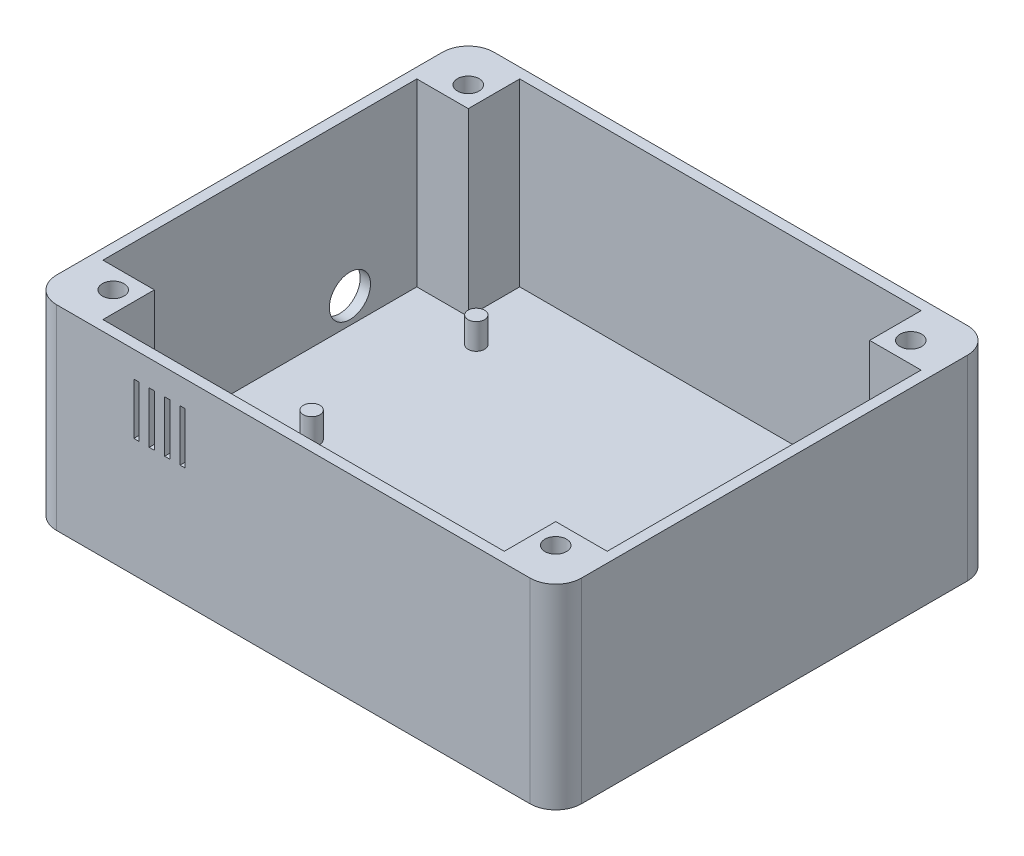
from build123d import *

# Parameters (mm, degrees)
SKETCH1_W           = 102
SKETCH1_H           = 85
BOSS_EXTRUDE1_DEPTH = 38
SKETCH2_R           = 2.1
CUT_EXTRUDE1_DEPTH  = 35
SKETCH3_R           = 2.1
CUT_EXTRUDE2_DEPTH  = 35
SKETCH5_R           = 4
CUT_EXTRUDE4_DEPTH  = 10
FILLET1_R           = 5
FILLET2_R           = 5
FILLET3_R           = 5
FILLET4_R           = 5
SKETCH6_R           = 1.6
BOSS_EXTRUDE2_DEPTH = 5
SKETCH7_W           = 15
SKETCH7_H           = 4
BOSS_EXTRUDE3_DEPTH = 12
CHAMFER1_SIZE       = 5
CHAMFER2_SIZE       = 5
SKETCH8_R           = 3.012300636
CUT_EXTRUDE5_DEPTH  = 5
FILLET5_R           = 2
FILLET6_R           = 2
FILLET7_R           = 2
FILLET8_R           = 2
SKETCH9_W           = 1
SKETCH9_H           = 10
CUT_EXTRUDE6_DEPTH  = 2.1
SKETCH10_W          = 1
SKETCH10_H          = 10
CUT_EXTRUDE7_DEPTH  = 2.1


with BuildPart() as part:
    # Sketch1 → Boss-Extrude1 (new body)
    with BuildSketch(Plane(origin=(0, 0, 0), x_dir=(1, 0, 0), z_dir=(0, 1, 0))):
        Rectangle(SKETCH1_W, SKETCH1_H)
    extrude(amount=BOSS_EXTRUDE1_DEPTH)

    # Sketch2 → Cut-Extrude1 (cut)
    with BuildSketch(Plane(origin=(0, 38, 0), x_dir=(1, 0, 0), z_dir=(0, 1, 0))):
        with Locations((43, 34.5)):
            Circle(SKETCH2_R)
        with Locations((-43, -34.5)):
            Circle(SKETCH2_R)
        with Locations((43, -34.5)):
            Circle(SKETCH2_R)
        Polygon((-39, 40.5), (39, 40.5), (39, 30.5), (49, 30.5), (49, -30.5), (39, -30.5), (39, -40.5), (-39, -40.5), (-39, -30.5), (-49, -30.5), (-49, 30.5), (-39, 30.5), align=None)
    extrude(amount=-CUT_EXTRUDE1_DEPTH, mode=Mode.SUBTRACT)

    # Sketch3 → Cut-Extrude2 (cut)
    with BuildSketch(Plane(origin=(0, 38, 0), x_dir=(1, 0, 0), z_dir=(0, 1, 0))):
        with Locations((-43, 34.5)):
            Circle(SKETCH3_R)
    extrude(amount=-CUT_EXTRUDE2_DEPTH, mode=Mode.SUBTRACT)

    # Sketch5 → Cut-Extrude4 (cut)
    with BuildSketch(Plane.ZY.offset(51)):
        with Locations((-17.5, 7.998461061)):
            Circle(SKETCH5_R)
        with Locations((17.5, 7.998461061)):
            Circle(SKETCH5_R)
    extrude(amount=-CUT_EXTRUDE4_DEPTH, mode=Mode.SUBTRACT)

    # Fillet1
    fillet1_edges = [part.edges().sort_by_distance(p)[0] for p in [
        (-51, 19, 42.5),
    ]]
    fillet(fillet1_edges, radius=FILLET1_R)

    # Fillet2
    fillet2_edges = [part.edges().sort_by_distance(p)[0] for p in [
        (-51, 19, -42.5),
    ]]
    fillet(fillet2_edges, radius=FILLET2_R)

    # Fillet3
    fillet3_edges = [part.edges().sort_by_distance(p)[0] for p in [
        (51, 19, 42.5),
    ]]
    fillet(fillet3_edges, radius=FILLET3_R)

    # Fillet4
    fillet4_edges = [part.edges().sort_by_distance(p)[0] for p in [
        (51, 19, -42.5),
    ]]
    fillet(fillet4_edges, radius=FILLET4_R)

    # Sketch6 → Boss-Extrude2 (add)
    with BuildSketch(Plane(origin=(0, 3, 0), x_dir=(1, 0, 0), z_dir=(0, 1, 0))):
        with Locations((-33.5, 26.565019739)):
            Circle(SKETCH6_R)
        with Locations((-33.5, -5.434980261)):
            Circle(SKETCH6_R)
        with Locations((33.5, 26.565019739)):
            Circle(SKETCH6_R)
        with Locations((33.5, -5.434980261)):
            Circle(SKETCH6_R)
    extrude(amount=BOSS_EXTRUDE2_DEPTH)

    # Sketch7 → Boss-Extrude3 (add)
    with BuildSketch(Plane.ZY.offset(51)):
        with Locations((0, 2)):
            Rectangle(SKETCH7_W, SKETCH7_H)
    extrude(amount=BOSS_EXTRUDE3_DEPTH)

    # Chamfer1
    chamfer1_edges = [part.edges().sort_by_distance(p)[0] for p in [
        (-63, 2, -7.5),
    ]]
    chamfer(chamfer1_edges, length=CHAMFER1_SIZE)

    # Chamfer2
    chamfer2_edges = [part.edges().sort_by_distance(p)[0] for p in [
        (-63, 2, 7.5),
    ]]
    chamfer(chamfer2_edges, length=CHAMFER2_SIZE)

    # Sketch8 → Cut-Extrude5 (cut)
    with BuildSketch(Plane(origin=(0, 4, 0), x_dir=(1, 0, 0), z_dir=(0, 1, 0))):
        with Locations((-56.61368814, 0)):
            Circle(SKETCH8_R)
    extrude(amount=-CUT_EXTRUDE5_DEPTH, mode=Mode.SUBTRACT)

    # Fillet5
    fillet5_edges = [part.edges().sort_by_distance(p)[0] for p in [
        (-58, 2, -7.5),
    ]]
    fillet(fillet5_edges, radius=FILLET5_R)

    # Fillet6
    fillet6_edges = [part.edges().sort_by_distance(p)[0] for p in [
        (-63, 2, -2.5),
    ]]
    fillet(fillet6_edges, radius=FILLET6_R)

    # Fillet7
    fillet7_edges = [part.edges().sort_by_distance(p)[0] for p in [
        (-63, 2, 2.5),
    ]]
    fillet(fillet7_edges, radius=FILLET7_R)

    # Fillet8
    fillet8_edges = [part.edges().sort_by_distance(p)[0] for p in [
        (-58, 2, 7.5),
    ]]
    fillet(fillet8_edges, radius=FILLET8_R)

    # Sketch9 → Cut-Extrude6 (cut)
    with BuildSketch(Plane.XY.offset(42.5)):
        with Locations((-30.5, 28)):
            Rectangle(SKETCH9_W, SKETCH9_H)
    extrude(amount=-CUT_EXTRUDE6_DEPTH, mode=Mode.SUBTRACT)

    # Sketch10 → Cut-Extrude7 (cut)
    with BuildSketch(Plane.XY.offset(42.5)):
        with Locations((-27.5, 28)):
            Rectangle(SKETCH10_W, SKETCH10_H)
        with Locations((-24.5, 28)):
            Rectangle(SKETCH10_W, SKETCH10_H)
        with Locations((-21.5, 28)):
            Rectangle(SKETCH10_W, SKETCH10_H)
    extrude(amount=-CUT_EXTRUDE7_DEPTH, mode=Mode.SUBTRACT)


solid = part.part
